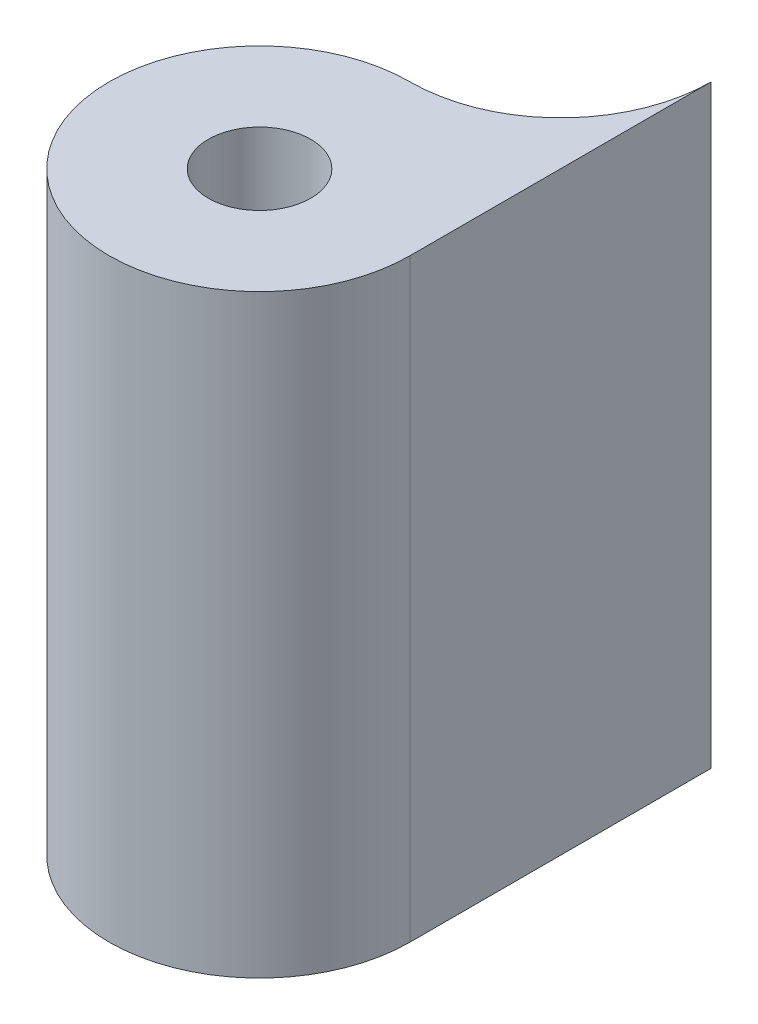
from build123d import *

# Parameters (mm, degrees)
BOSS_EXTRUDE1_DEPTH      = 20
SHELL1_T                 = -10
SHELL1_THICKNESS_2_DEPTH = 6
SKETCH3_R                = 32.5
CUT_EXTRUDE5_DEPTH       = 119.84864324
CUT_EXTRUDE6_DEPTH       = 119.84864324
SKETCH5_R                = 17.5
CUT_EXTRUDE7_DEPTH       = 119.84864324
SKETCH6_R                = 1.7
BOSS_EXTRUDE2_DEPTH      = 50
SKETCH6_2_R              = 1.7
CUT_EXTRUDE8_DEPTH       = 35
SKETCH9_R                = 1.7
BOSS_EXTRUDE3_DEPTH      = 32.5
SKETCH9_2_R              = 1.7
CUT_EXTRUDE10_DEPTH      = 12.75
CUT_EXTRUDE9_DEPTH       = 2
FILLET1_R                = 5
FILLET2_R                = 0.5
SKETCH10_W               = 46.141745146
SKETCH10_H               = 188.45260123
CUT_EXTRUDE11_DEPTH      = 186.270073136


with BuildPart() as part:
    # Sketch1 → Boss-Extrude1 (new body)
    with BuildSketch(Plane.XY):
        with BuildLine():
            Line((55, -90), (-55, -90))
            ThreePointArc((-55, -90), (-69.142135624, -84.142135624), (-75, -70))
            Line((-75, -70), (-75, 70))
            ThreePointArc((-75, 70), (-69.142135624, 84.142135624), (-55, 90))
            Line((-55, 90), (55, 90))
            ThreePointArc((55, 90), (69.142135624, 84.142135624), (75, 70))
            Line((75, 70), (75, -70))
            ThreePointArc((75, -70), (69.142135624, -84.142135624), (55, -90))
        make_face()
    extrude(amount=BOSS_EXTRUDE1_DEPTH)

    # Shell1
    shell1_openings = [part.faces().sort_by_distance(p)[0] for p in [
        (0, 0, 20),
    ]]
    offset(amount=SHELL1_T, openings=shell1_openings, kind=Kind.INTERSECTION)

    # Shell1 thickness 2 face (on inner face of the shell) → Shell1 thickness 2 (cut)
    with BuildSketch(Plane(origin=(0, 0, 10), x_dir=(-1, 0, 0), z_dir=(0, 0, -1))):
        with BuildLine():
            ThreePointArc((-55, -80), (-62.071067812, -77.071067812), (-65, -70))
            Line((-65, -70), (-65, 70))
            ThreePointArc((-65, 70), (-62.071067812, 77.071067812), (-55, 80))
            Line((-55, 80), (55, 80))
            ThreePointArc((55, 80), (62.071067812, 77.071067812), (65, 70))
            Line((65, 70), (65, -70))
            ThreePointArc((65, -70), (62.071067812, -77.071067812), (55, -80))
            Line((55, -80), (-55, -80))
        make_face()
    extrude(amount=SHELL1_THICKNESS_2_DEPTH, mode=Mode.SUBTRACT)

    # Sketch3 → Cut-Extrude5 (cut, through all)
    with BuildSketch(Plane.XY):
        with Locations((0, -36.75)):
            Circle(SKETCH3_R)
    extrude(amount=CUT_EXTRUDE5_DEPTH, mode=Mode.SUBTRACT)

    # Sketch4 → Cut-Extrude6 (cut, through all)
    with BuildSketch(Plane.XY):
        with BuildLine():
            Line((-30.75, 13.25), (-9.25, 13.25))
            ThreePointArc((-9.25, 13.25), (-8.542893219, 13.542893219), (-8.25, 14.25))
            Line((-8.25, 14.25), (-8.25, 35.75))
            ThreePointArc((-8.25, 35.75), (-8.542893219, 36.457106781), (-9.25, 36.75))
            Line((-9.25, 36.75), (-30.75, 36.75))
            ThreePointArc((-30.75, 36.75), (-31.457106781, 36.457106781), (-31.75, 35.75))
            Line((-31.75, 35.75), (-31.75, 14.25))
            ThreePointArc((-31.75, 14.25), (-31.457106781, 13.542893219), (-30.75, 13.25))
        make_face()
    extrude(amount=CUT_EXTRUDE6_DEPTH, mode=Mode.SUBTRACT)

    # Sketch5 → Cut-Extrude7 (cut, through all)
    with BuildSketch(Plane.XY):
        with Locations((20, 25)):
            Circle(SKETCH5_R)
    extrude(amount=CUT_EXTRUDE7_DEPTH, mode=Mode.SUBTRACT)

    # Sketch6 → Boss-Extrude2 (add, symmetric)
    with BuildSketch(Plane(origin=(0, 0, 0), x_dir=(1, 0, 0), z_dir=(0, 1, 0))):
        with BuildLine():
            Line((75, -20), (75, -10))
            ThreePointArc((75, -10), (76.464466094, -13.535533906), (80, -15))
            ThreePointArc((80, -15), (83.535533906, -23.535533906), (75, -20))
        make_face()
        with Locations((80, -20)):
            Circle(SKETCH6_R, mode=Mode.SUBTRACT)
    extrude(amount=BOSS_EXTRUDE2_DEPTH, both=True)

    # Sketch6_2 → Cut-Extrude8 (cut, symmetric)
    with BuildSketch(Plane(origin=(0, 0, 0), x_dir=(1, 0, 0), z_dir=(0, 1, 0))):
        with BuildLine():
            Line((75, -20), (75, -10))
            ThreePointArc((75, -10), (76.464466094, -13.535533906), (80, -15))
            ThreePointArc((80, -15), (83.535533906, -23.535533906), (75, -20))
        make_face()
        with Locations((80, -20)):
            Circle(SKETCH6_2_R, mode=Mode.SUBTRACT)
    extrude(amount=CUT_EXTRUDE8_DEPTH, both=True, mode=Mode.SUBTRACT)

    # Sketch9 → Boss-Extrude3 (add, symmetric)
    with BuildSketch(Plane(origin=(0, 0, 0), x_dir=(1, 0, 0), z_dir=(0, 1, 0))):
        with BuildLine():
            Line((-75, -10), (-75, -20))
            ThreePointArc((-75, -20), (-83.535533906, -23.535533906), (-80, -15))
            ThreePointArc((-80, -15), (-76.464466094, -13.535533906), (-75, -10))
        make_face()
        with Locations((-80, -20)):
            Circle(SKETCH9_R, mode=Mode.SUBTRACT)
    extrude(amount=BOSS_EXTRUDE3_DEPTH, both=True)

    # Sketch9_2 → Cut-Extrude10 (cut, symmetric)
    with BuildSketch(Plane(origin=(0, 0, 0), x_dir=(1, 0, 0), z_dir=(0, 1, 0))):
        with BuildLine():
            Line((-75, -10), (-75, -20))
            ThreePointArc((-75, -20), (-83.535533906, -23.535533906), (-80, -15))
            ThreePointArc((-80, -15), (-76.464466094, -13.535533906), (-75, -10))
        make_face()
        with Locations((-80, -20)):
            Circle(SKETCH9_2_R, mode=Mode.SUBTRACT)
    extrude(amount=CUT_EXTRUDE10_DEPTH, both=True, mode=Mode.SUBTRACT)

    # Sketch7 → Cut-Extrude9 (cut)
    with BuildSketch(Plane.XY.offset(4)):
        with BuildLine():
            Line((-26, -0.75), (26, -0.75))
            ThreePointArc((26, -0.75), (33.071067812, -3.678932188), (36, -10.75))
            Line((36, -10.75), (36, -62.75))
            ThreePointArc((36, -62.75), (33.071067812, -69.821067812), (26, -72.75))
            Line((26, -72.75), (-26, -72.75))
            ThreePointArc((-26, -72.75), (-33.071067812, -69.821067812), (-36, -62.75))
            Line((-36, -62.75), (-36, -10.75))
            ThreePointArc((-36, -10.75), (-33.071067812, -3.678932188), (-26, -0.75))
        make_face()
        with BuildLine():
            Line((8, 47), (32, 47))
            ThreePointArc((32, 47), (39.071067812, 44.071067812), (42, 37))
            Line((42, 37), (42, 13))
            ThreePointArc((42, 13), (39.071067812, 5.928932188), (32, 3))
            Line((32, 3), (8, 3))
            ThreePointArc((8, 3), (0.928932188, 5.928932188), (-2, 13))
            Line((-2, 13), (-2, 37))
            ThreePointArc((-2, 37), (0.928932188, 44.071067812), (8, 47))
        make_face()
    extrude(amount=-CUT_EXTRUDE9_DEPTH, mode=Mode.SUBTRACT)

    # Fillet1
    fillet1_edges = [part.edges().sort_by_distance(p)[0] for p in [
        (75, 0, 0),
        (69.142135624, -84.142135624, 0),
        (0, -90, 0),
        (-69.142135624, -84.142135624, 0),
        (-75, 0, 0),
        (-69.142135624, 84.142135624, 0),
        (0, 90, 0),
        (69.142135624, 84.142135624, 0),
        (0, 80, 4),
        (62.071067812, 77.071067812, 4),
        (65, 0, 4),
        (62.071067812, -77.071067812, 4),
        (0, -80, 4),
        (-62.071067812, -77.071067812, 4),
        (-65, 0, 4),
        (-62.071067812, 77.071067812, 4),
    ]]
    fillet(fillet1_edges, radius=FILLET1_R)

    # Fillet2
    fillet2_edges = [part.edges().sort_by_distance(p)[0] for p in [
        (-8.542893219, 13.542893219, 0),
        (-20, 13.25, 0),
        (-31.457106781, 13.542893219, 0),
        (-31.75, 25, 0),
        (-31.457106781, 36.457106781, 0),
        (-20, 36.75, 0),
        (-8.542893219, 36.457106781, 0),
        (75, 60, 20),
        (69.142135624, 84.142135624, 20),
        (0, 90, 20),
        (-69.142135624, 84.142135624, 20),
        (75, -60, 20),
        (69.142135624, -84.142135624, 20),
        (0, -90, 20),
        (-69.142135624, -84.142135624, 20),
        (-62.071067812, 77.071067812, 20),
        (0, 80, 20),
        (62.071067812, 77.071067812, 20),
        (65, 0, 20),
        (62.071067812, -77.071067812, 20),
        (0, -80, 20),
        (-62.071067812, -77.071067812, 20),
        (-8.25, 25, 0),
        (2.5, 25, 0),
        (75, 0, 20),
        (-75, 51.25, 20),
        (-75, -51.25, 20),
        (-75, 0, 20),
        (-65, 0, 20),
        (-32.5, -36.75, 0),
        (0.928932188, 44.071067812, 4),
        (20, 47, 4),
        (39.071067812, 44.071067812, 4),
        (42, 25, 4),
        (39.071067812, 5.928932188, 4),
        (20, 3, 4),
        (0.928932188, 5.928932188, 4),
        (33.071067812, -3.678932188, 4),
        (36, -36.75, 4),
        (33.071067812, -69.821067812, 4),
        (0, -72.75, 4),
        (-33.071067812, -69.821067812, 4),
        (-36, -36.75, 4),
        (-33.071067812, -3.678932188, 4),
        (-2, 25, 4),
        (0, -0.75, 4),
    ]]
    fillet(fillet2_edges, radius=FILLET2_R)

    # Sketch10 → Cut-Extrude11 (cut, through all)
    with BuildSketch(Plane.ZY.offset(75)):
        with Locations((9.585784517, 0.121425645)):
            Rectangle(SKETCH10_W, SKETCH10_H)
    extrude(amount=-CUT_EXTRUDE11_DEPTH, mode=Mode.SUBTRACT)


with BuildPart() as body_2:
    # of the pieces the cut leaves, the one that is kept (cut_extrude11_keep)
    add(part.part.solids().sort_by_distance((-75, 12.75, 20))[0])


solid = body_2.part
